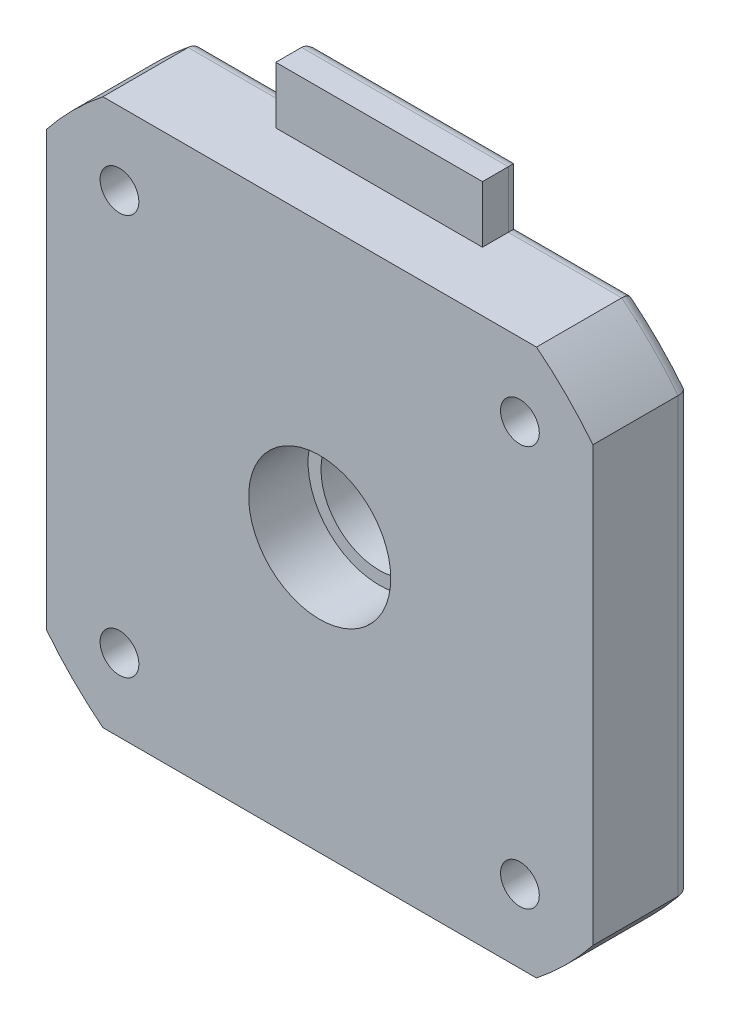
from build123d import *

# Parameters (mm, degrees)
CROQUIS1_W            = 42.3
CROQUIS1_H            = 42.3
EXTRUDE_FEATURE_DEPTH = 7.6
SKETCH2_R             = 29.910616844
SKETCH2_R_2           = 27
CUT_EXTRUDE1_DEPTH    = 8.6
CROQUIS5_R            = 1.5
CORTAR_EXTRUIR2_DEPTH = 22
CROQUIS6_R            = 4.5
CORTAR_EXTRUIR3_DEPTH = 8.6
SKETCH3_R             = 5.5
CUT_EXTRUDE2_DEPTH    = 4.6
CROQUIS7_R            = 3
CORTAR_EXTRUIR4_DEPTH = 3
SKETCH1_W             = 16
SKETCH1_H             = 4.4
BOSS_EXTRUDE1_DEPTH   = 3
FILLET1_R             = 1
CHAMFER1_SIZE         = 0.5


with BuildPart() as part:
    # Croquis1 → Extrude Feature (new body)
    with BuildSketch(Plane.XY):
        Rectangle(CROQUIS1_W, CROQUIS1_H)
    extrude(amount=EXTRUDE_FEATURE_DEPTH)

    # Sketch2 → Cut-Extrude1 (cut, through all)
    with BuildSketch(Plane.XY.offset(7.6)):
        Circle(SKETCH2_R)
        Circle(SKETCH2_R_2, mode=Mode.SUBTRACT)
    extrude(amount=-CUT_EXTRUDE1_DEPTH, mode=Mode.SUBTRACT)

    # Croquis5 → Cortar-Extruir2 (cut)
    with BuildSketch(Plane(origin=(0, 0, 0), x_dir=(-1, 0, 0), z_dir=(0, 0, -1))):
        with Locations((-15.5, 15.5)):
            Circle(CROQUIS5_R)
        with Locations((15.5, 15.5)):
            Circle(CROQUIS5_R)
        with Locations((15.5, -15.5)):
            Circle(CROQUIS5_R)
        with Locations((-15.5, -15.5)):
            Circle(CROQUIS5_R)
    extrude(amount=-CORTAR_EXTRUIR2_DEPTH, mode=Mode.SUBTRACT)

    # Croquis6 → Cortar-Extruir3 (cut, through all)
    with BuildSketch(Plane(origin=(0, 0, 0), x_dir=(-1, 0, 0), z_dir=(0, 0, -1))):
        Circle(CROQUIS6_R)
    extrude(amount=-CORTAR_EXTRUIR3_DEPTH, mode=Mode.SUBTRACT)

    # Sketch3 → Cut-Extrude2 (cut)
    with BuildSketch(Plane.XY.offset(7.6)):
        Circle(SKETCH3_R)
    extrude(amount=-CUT_EXTRUDE2_DEPTH, mode=Mode.SUBTRACT)

    # Croquis7 → Cortar-Extruir4 (cut)
    with BuildSketch(Plane(origin=(0, 0, 0), x_dir=(-1, 0, 0), z_dir=(0, 0, -1))):
        with Locations((-15.5, 15.5)):
            Circle(CROQUIS7_R)
        with Locations((15.5, 15.5)):
            Circle(CROQUIS7_R)
        with Locations((15.5, -15.5)):
            Circle(CROQUIS7_R)
        with Locations((-15.5, -15.5)):
            Circle(CROQUIS7_R)
    extrude(amount=-CORTAR_EXTRUIR4_DEPTH, mode=Mode.SUBTRACT)

    # Sketch1 → Boss-Extrude1 (add)
    with BuildSketch(Plane(origin=(0, 0, 0), x_dir=(-1, 0, 0), z_dir=(0, 0, -1))):
        with Locations((0, 23.35)):
            Rectangle(SKETCH1_W, SKETCH1_H)
    extrude(amount=-BOSS_EXTRUDE1_DEPTH)

    # Fillet1
    fillet1_edges = [part.edges().sort_by_distance(p)[0] for p in [
        (-12.39162529, 21.15, 0),
        (-8, 23.35, 0),
        (0, 25.55, 0),
        (8, 23.35, 0),
        (21.15, 0, 0),
        (0, -21.15, 0),
        (-21.15, 0, 0),
        (12.39162529, 21.15, 0),
        (19.091883092, -19.091883092, 0),
        (-19.091883092, -19.091883092, 0),
        (-19.091883092, 19.091883092, 0),
        (19.091883092, 19.091883092, 0),
    ]]
    fillet(fillet1_edges, radius=FILLET1_R)

    # Chamfer1
    chamfer1_edges = [part.edges().sort_by_distance(p)[0] for p in [
        (18.5, 15.5, 0),
        (-12.5, 15.5, 0),
        (-12.5, -15.5, 0),
        (18.5, -15.5, 0),
    ]]
    chamfer(chamfer1_edges, length=CHAMFER1_SIZE)


solid = part.part
